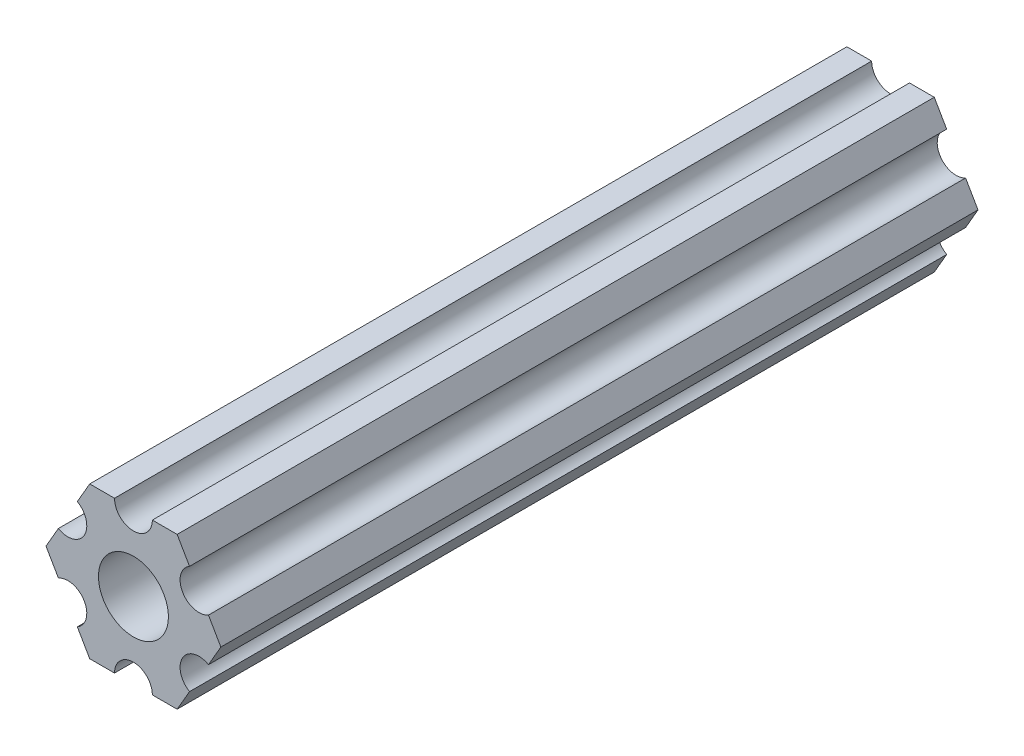
from build123d import *

# Parameters (mm, degrees)
SKETCH1_R           = 2.9337
BOSS_EXTRUDE1_DEPTH = 63.5


with BuildPart() as part:
    # Sketch1 → Boss-Extrude1 (new body)
    with BuildSketch(Plane(origin=(0, 0, 0), x_dir=(-1, 0, 0), z_dir=(0, 0, -1))):
        with BuildLine():
            Line((-7.332348419, 4.44e-07), (-6.293011423, -1.80018429))
            ThreePointArc((-6.293011423, -1.80018429), (-4.12444613, -2.38124975), (-4.70551159, -4.549815043))
            Line((-4.70551159, -4.549815043), (-3.666174594, -6.349999778))
            Line((-3.666174594, -6.349999778), (-1.587500385, -6.349999778))
            ThreePointArc((-1.587500385, -6.349999778), (-3.85e-07, -4.762499778), (1.587499615, -6.349999778))
            Line((1.587499615, -6.349999778), (3.666173825, -6.349999778))
            Line((3.666173825, -6.349999778), (4.705510929, -4.549815106))
            ThreePointArc((4.705510929, -4.549815106), (4.124445601, -2.381249778), (6.293010929, -1.800184449))
            Line((6.293010929, -1.800184449), (7.332348034, 2.22e-07))
            Line((7.332348034, 2.22e-07), (6.293011189, 1.800184821))
            ThreePointArc((6.293011189, 1.800184821), (4.124445913, 2.381250347), (4.705511439, 4.549815623))
            Line((4.705511439, 4.549815623), (3.666174594, 6.350000222))
            Line((3.666174594, 6.350000222), (1.587500385, 6.350000222))
            ThreePointArc((1.587500385, 6.350000222), (3.85e-07, 4.762500222), (-1.587499615, 6.350000222))
            Line((-1.587499615, 6.350000222), (-3.666173825, 6.350000222))
            Line((-3.666173825, 6.350000222), (-4.705511038, 4.549815614))
            ThreePointArc((-4.705511038, 4.549815614), (-4.124445841, 2.38125025), (-6.293011205, 1.800185053))
            Line((-6.293011205, 1.800185053), (-7.332348419, 4.44e-07))
        make_face()
        Circle(SKETCH1_R, mode=Mode.SUBTRACT)
    extrude(amount=-BOSS_EXTRUDE1_DEPTH)


solid = part.part
